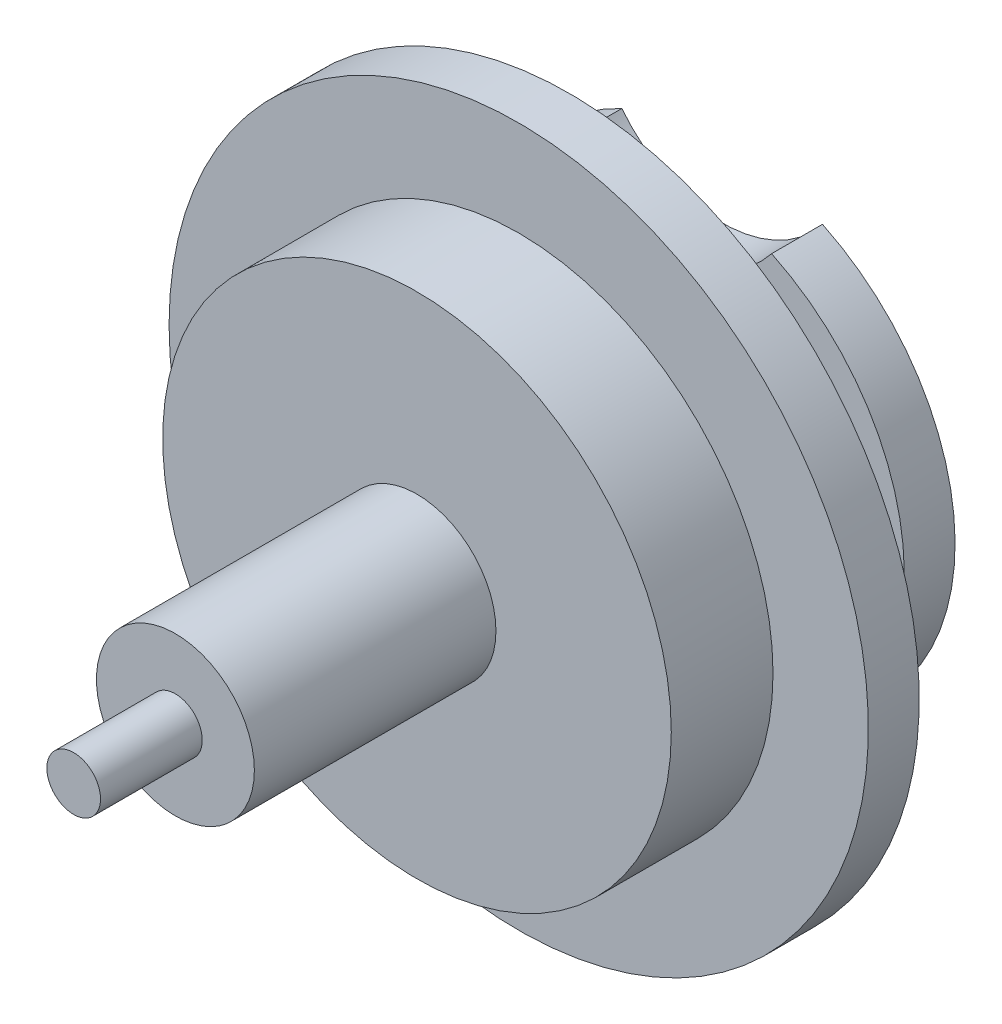
from build123d import *

# Parameters (mm, degrees)
SKETCH1_R                = 0.3105
BOSS_EXTRUDE1_DEPTH      = 0.95
BOSS_EXTRUDE1_DEPTH_BACK = 1.35
SKETCH2_R                = 0.1055
BOSS_EXTRUDE2_DEPTH      = 1.35
SKETCH2_2_R              = 0.1055
BOSS_EXTRUDE3_DEPTH      = 1.75
SKETCH3_R                = 1
BOSS_EXTRUDE4_DEPTH      = 0.4
SKETCH4_R                = 1.375
BOSS_EXTRUDE5_DEPTH      = 0.2
BOSS_EXTRUDE6_START      = -1
SKETCH5_R                = 0.916
BOSS_EXTRUDE6_DEPTH      = 0.2
SKETCH6_R                = 0.5
CUT_EXTRUDE1_DEPTH       = 0.2
SKETCH7_RX               = 0.246
SKETCH7_RY               = 0.078
CUT_EXTRUDE2_DEPTH       = 0.15


with BuildPart() as part:
    # Sketch1 → Boss-Extrude1 (new body, two sides)
    with BuildSketch(Plane.XY) as boss_extrude1_sk:
        Circle(SKETCH1_R)
    extrude(amount=BOSS_EXTRUDE1_DEPTH)
    extrude(boss_extrude1_sk.sketch, amount=-BOSS_EXTRUDE1_DEPTH_BACK)

    # Sketch2 → Boss-Extrude2 (add)
    with BuildSketch(Plane.XY):
        Circle(SKETCH2_R)
    extrude(amount=BOSS_EXTRUDE2_DEPTH)

    # Sketch2_2 → Boss-Extrude3 (add)
    with BuildSketch(Plane.XY):
        Circle(SKETCH2_2_R)
    extrude(amount=-BOSS_EXTRUDE3_DEPTH)

    # Sketch3 → Boss-Extrude4 (add)
    with BuildSketch(Plane.XY):
        Circle(SKETCH3_R)
    extrude(amount=-BOSS_EXTRUDE4_DEPTH)

    # Sketch4 → Boss-Extrude5 (add)
    with BuildSketch(Plane(origin=(0, 0, -0.4), x_dir=(-1, 0, 0), z_dir=(0, 0, -1))):
        Circle(SKETCH4_R)
    extrude(amount=BOSS_EXTRUDE5_DEPTH)

    # Sketch5 → Boss-Extrude6 (add)
    with BuildSketch(Plane.XY.offset(BOSS_EXTRUDE6_START)):
        Circle(SKETCH5_R)
    extrude(amount=-BOSS_EXTRUDE6_DEPTH)

    # Sketch6 → Cut-Extrude1 (cut)
    with BuildSketch(Plane(origin=(0, 0, -1.2), x_dir=(-1, 0, 0), z_dir=(0, 0, -1))):
        with Locations((0, 1.134)):
            Circle(SKETCH6_R)
    extrude(amount=-CUT_EXTRUDE1_DEPTH, mode=Mode.SUBTRACT)

    # Sketch7 → Cut-Extrude2 (cut)
    with BuildSketch(Plane(origin=(0, 0, -0.6), x_dir=(-1, 0, 0), z_dir=(0, 0, -1))):
        with Locations(Location((0, 1.043666416), (0, 0, 0.077694932))):
            Ellipse(SKETCH7_RX, SKETCH7_RY)
    extrude(amount=-CUT_EXTRUDE2_DEPTH, mode=Mode.SUBTRACT)


solid = part.part
